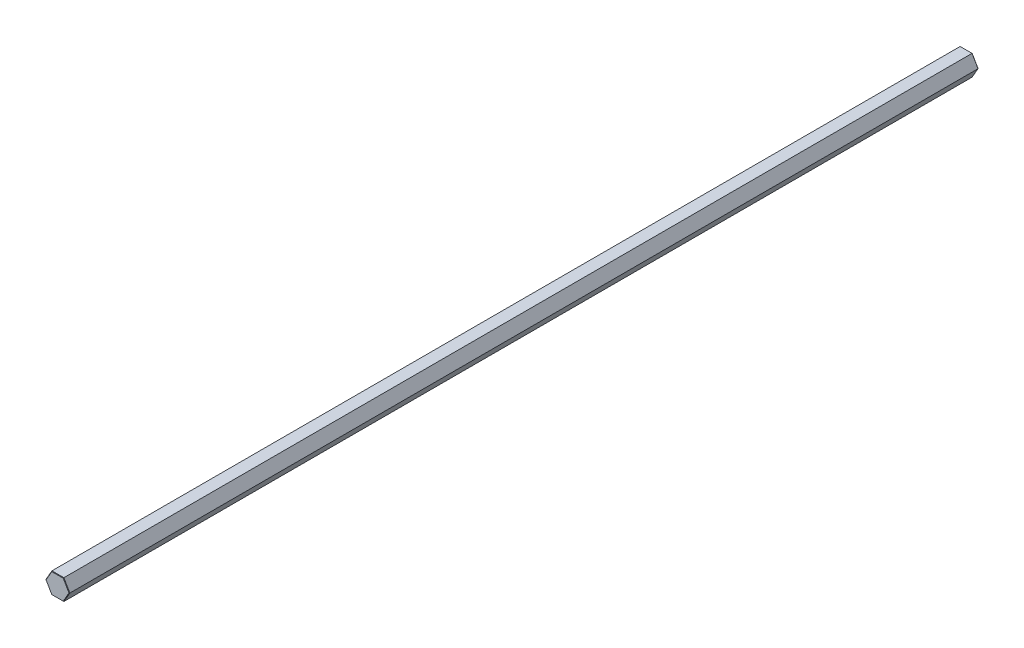
from build123d import *

# Parameters (mm, degrees)
BOSS_EXTRUDE1_DEPTH = 558.8
CHAMFER1_SIZE       = 0.254


with BuildPart() as part:
    # Sketch1 → Boss-Extrude1 (new body)
    with BuildSketch(Plane(origin=(0, 0, 0), x_dir=(-1, 0, 0), z_dir=(0, 0, -1))):
        Polygon((3.666174209, 6.35), (-3.666174209, 6.35), (-7.332348419, 0), (-3.666174209, -6.35), (3.666174209, -6.35), (7.332348419, 0), align=None)
    extrude(amount=-BOSS_EXTRUDE1_DEPTH)

    # Chamfer1
    chamfer1_edges = [part.edges().sort_by_distance(p)[0] for p in [
        (5.499261314, 3.175, 558.8),
        (5.499261314, -3.175, 558.8),
        (0, -6.35, 558.8),
        (-5.499261314, -3.175, 558.8),
        (-5.499261314, 3.175, 558.8),
        (-5.499261314, -3.175, 0),
        (0, -6.35, 0),
        (5.499261314, -3.175, 0),
        (5.499261314, 3.175, 0),
        (0, 6.35, 0),
        (-5.499261314, 3.175, 0),
        (0, 6.35, 558.8),
    ]]
    chamfer(chamfer1_edges, length=CHAMFER1_SIZE)


solid = part.part
